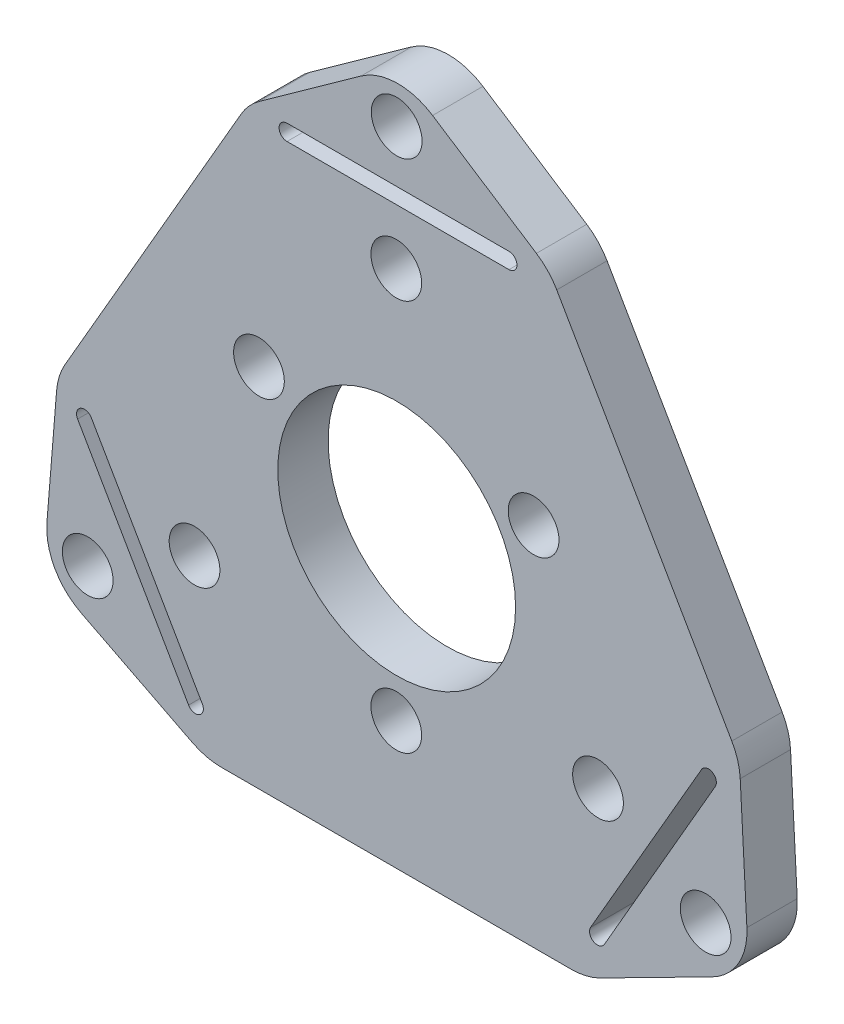
from build123d import *

# Parameters (mm, degrees)
SKETCH1_R           = 1.6
BOSS_EXTRUDE1_DEPTH = 3.175
SKETCH2_R           = 1.6
SKETCH2_R_2         = 7.5
CUT_EXTRUDE1_DEPTH  = 4.175


with BuildPart() as part:
    # Sketch1 → Boss-Extrude1 (new body)
    with BuildSketch(Plane.XY):
        with BuildLine():
            Line((31.086717458, 32.79124845), (24.539210672, 37.049362302))
            ThreePointArc((24.539210672, 37.049362302), (22.268882249, 37.695107847), (20.029743315, 36.948358029))
            Line((20.029743315, 36.948358029), (13.602836128, 32.346493758))
            ThreePointArc((13.602836128, 32.346493758), (12.968237383, 31.781029757), (12.467444066, 31.094246563))
            Line((12.467444066, 31.094246563), (1.349560594, 11.837507517))
            ThreePointArc((1.349560594, 11.837507517), (0.995156132, 11.028730142), (0.826837821, 10.16190126))
            Line((0.826837821, 10.16190126), (0.217529035, 2.673448792))
            ThreePointArc((0.217529035, 2.673448792), (0.712425098, 0.398045931), (2.390731369, -1.216162343))
            Line((2.390731369, -1.216162343), (9.39530455, -4.779380795))
            ThreePointArc((9.39530455, -4.779380795), (10.276421795, -5.10394936), (11.208926603, -5.214163404))
            Line((11.208926603, -5.214163404), (33.291073397, -5.214163404))
            ThreePointArc((33.291073397, -5.214163404), (34.223578205, -5.10394936), (35.10469545, -4.779380795))
            Line((35.10469545, -4.779380795), (42.181392008, -1.179473262))
            ThreePointArc((42.181392008, -1.179473262), (43.83187157, 0.385744129), (44.362149812, 2.597710054))
            Line((44.362149812, 2.597710054), (43.941412908, 10.526262814))
            ThreePointArc((43.941412908, 10.526262814), (43.781938908, 11.451617014), (43.411134666, 12.314296889))
            Line((43.411134666, 12.314296889), (32.370061269, 31.437996983))
            ThreePointArc((32.370061269, 31.437996983), (31.808360702, 32.190462814), (31.086717458, 32.79124845))
        make_face()
        with Locations((13.589745962, 17.846043489)):
            Circle(SKETCH1_R, mode=Mode.SUBTRACT)
        with Locations((9.526279442, 5.5)):
            Circle(SKETCH1_R, mode=Mode.SUBTRACT)
        with Locations((34.973720558, 5.5)):
            Circle(SKETCH1_R, mode=Mode.SUBTRACT)
        with Locations((30.910254038, 17.846043489)):
            Circle(SKETCH1_R, mode=Mode.SUBTRACT)
        with Locations((22.25, 27.538130468)):
            Circle(SKETCH1_R, mode=Mode.SUBTRACT)
        with Locations((22.25, 2.846043489)):
            Circle(SKETCH1_R, mode=Mode.SUBTRACT)
        with BuildLine():
            Line((42.370834875, 9.312177826), (35.370834875, -2.812177826))
            ThreePointArc((35.370834875, -2.812177826), (34.687822174, -2.995190528), (34.504809472, -2.312177826))
            Line((34.504809472, -2.312177826), (41.504809472, 9.812177826))
            ThreePointArc((41.504809472, 9.812177826), (42.187822174, 9.995190528), (42.370834875, 9.312177826))
        make_face(mode=Mode.SUBTRACT)
        with BuildLine():
            Line((10.01754221, -2.349929674), (3.01754221, 9.774425979))
            ThreePointArc((3.01754221, 9.774425979), (2.334529508, 9.957438681), (2.151516806, 9.274425979))
            Line((2.151516806, 9.274425979), (9.151516806, -2.849929674))
            ThreePointArc((9.151516806, -2.849929674), (9.834529508, -3.032942376), (10.01754221, -2.349929674))
        make_face(mode=Mode.SUBTRACT)
        with BuildLine():
            Line((15.358452868, 31.038130468), (29.358452868, 31.038130468))
            ThreePointArc((29.358452868, 31.038130468), (29.858452868, 31.538130468), (29.358452868, 32.038130468))
            Line((29.358452868, 32.038130468), (15.358452868, 32.038130468))
            ThreePointArc((15.358452868, 32.038130468), (14.858452868, 31.538130468), (15.358452868, 31.038130468))
        make_face(mode=Mode.SUBTRACT)
    extrude(amount=BOSS_EXTRUDE1_DEPTH)

    # Sketch2 → Cut-Extrude1 (cut, through all)
    with BuildSketch(Plane.XY.offset(3.175)):
        with Locations((41.761034996, 1.563830145)):
            Circle(SKETCH2_R)
        with Locations((2.789891826, 1.563830145)):
            Circle(SKETCH2_R)
        with Locations((22.275463411, 12.813830145)):
            Circle(SKETCH2_R_2)
        with Locations((22.275463411, 35.313830145)):
            Circle(SKETCH2_R)
    extrude(amount=-CUT_EXTRUDE1_DEPTH, mode=Mode.SUBTRACT)


solid = part.part
